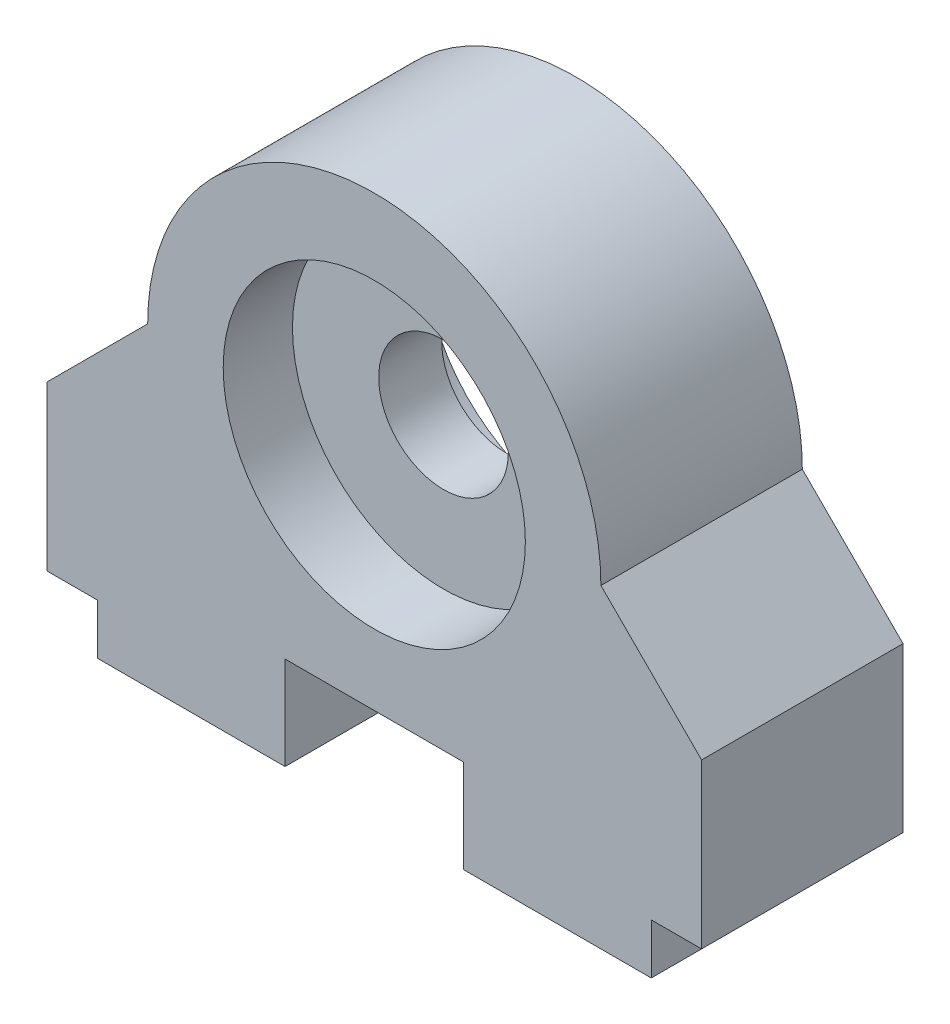
from build123d import *

# Parameters (mm, degrees)
SKETCH1_R                = 7.62
BOSS_EXTRUDE1_DEPTH      = 10.16
SKETCH3_R                = 8.7376
SKETCH3_R_2              = 3.27025
BOSS_EXTRUDE2_DEPTH      = 1.5875
BOSS_EXTRUDE2_DEPTH_BACK = 1.5875
SKETCH4_R                = 1.98374
CUT_EXTRUDE1_DEPTH       = 10.16


with BuildPart() as part:
    # Sketch1 → Boss-Extrude1 (new body)
    with BuildSketch(Plane.XY):
        with BuildLine():
            Line((4.5, 4.699), (-4.5, 4.699))
            Line((-4.5, 4.699), (-4.5, 0))
            Line((-4.5, 0), (-13.97, 0))
            Line((-13.97, 0), (-13.97, 2.54))
            Line((-13.97, 2.54), (-16.51, 2.54))
            Line((-16.51, 2.54), (-16.51, 10.795))
            Line((-16.51, 10.795), (-11.43, 15.875))
            ThreePointArc((-11.43, 15.875), (0, 27.305), (11.43, 15.875))
            Line((11.43, 15.875), (16.51, 10.795))
            Line((16.51, 10.795), (16.51, 2.54))
            Line((16.51, 2.54), (13.97, 2.54))
            Line((13.97, 2.54), (13.97, 0))
            Line((13.97, 0), (4.5, 0))
            Line((4.5, 0), (4.5, 4.699))
        make_face()
        with Locations((0, 15.875)):
            Circle(SKETCH1_R, mode=Mode.SUBTRACT)
    extrude(amount=BOSS_EXTRUDE1_DEPTH)

    # Sketch3 → Boss-Extrude2 (add, two sides)
    with BuildSketch(Plane.XY.offset(5.08)) as boss_extrude2_sk:
        with Locations((0, 15.875)):
            Circle(SKETCH3_R)
        with Locations((0, 15.875)):
            Circle(SKETCH3_R_2, mode=Mode.SUBTRACT)
    extrude(amount=BOSS_EXTRUDE2_DEPTH)
    extrude(boss_extrude2_sk.sketch, amount=-BOSS_EXTRUDE2_DEPTH_BACK)

    # Sketch4 → Cut-Extrude1 (cut)
    with BuildSketch(Plane(origin=(0, 0, 0), x_dir=(-1, 0, 0), z_dir=(0, -1, 0))):
        with Locations((-10.16, -3.81)):
            Circle(SKETCH4_R)
        with Locations((10.16, -3.81)):
            Circle(SKETCH4_R)
    extrude(amount=-CUT_EXTRUDE1_DEPTH, mode=Mode.SUBTRACT)


solid = part.part
